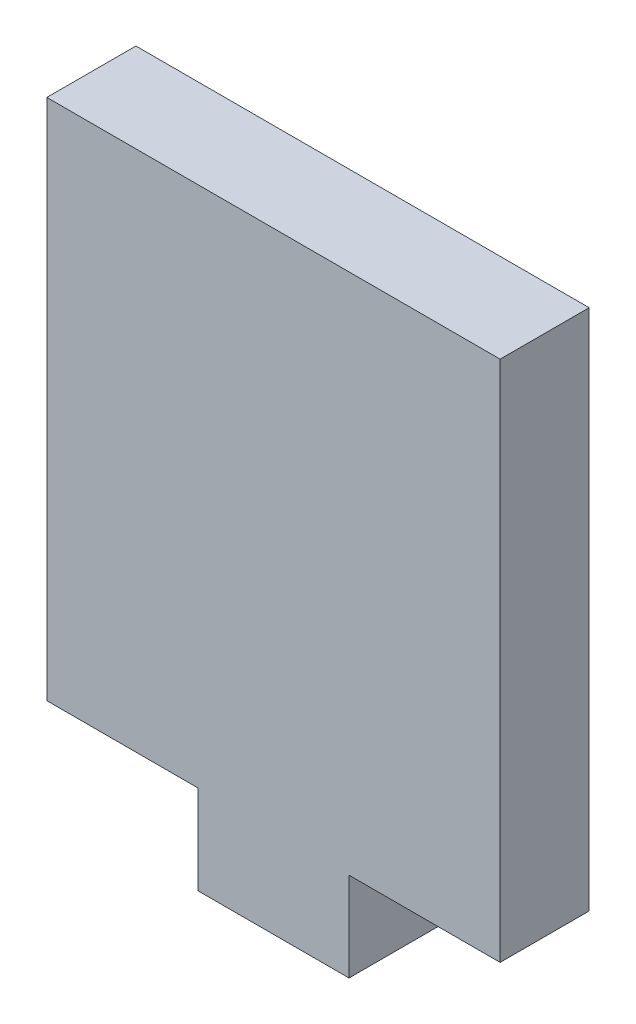
from build123d import *

# Parameters (mm, degrees)
BOSS_EXTRUDE1_DEPTH = 6


with BuildPart() as part:
    # Sketch1 → Boss-Extrude1 (new body)
    with BuildSketch(Plane.XY):
        Polygon((-41.491839967, 260.998518154), (-10.951839967, 260.998518154), (-10.951839967, 225.798518154), (-21.131839967, 225.798518154), (-21.131839967, 219.798518154), (-31.311839967, 219.798518154), (-31.311839967, 225.798518154), (-41.491839967, 225.798518154), align=None)
    extrude(amount=BOSS_EXTRUDE1_DEPTH)


solid = part.part
